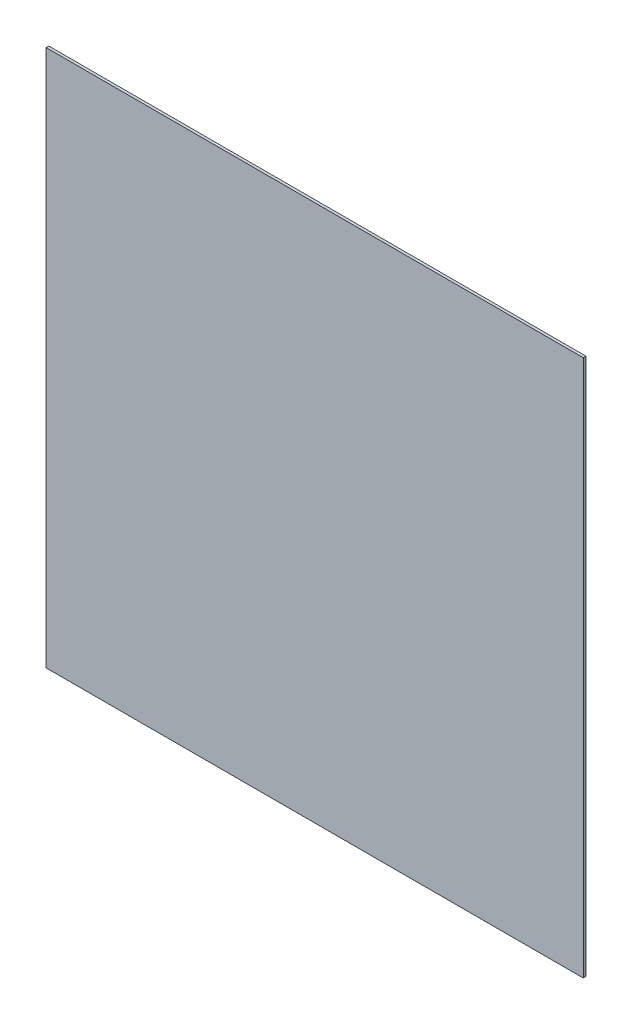
from build123d import *

# Parameters (mm, degrees)
SKETCH_1_W      = 200
SKETCH_1_H      = 200
EXTRUDE_1_DEPTH = 1


with BuildPart() as part:
    # 草图1 → 凸台-拉伸1 (new body)
    with BuildSketch(Plane.XY):
        Rectangle(SKETCH_1_W, SKETCH_1_H)
    extrude(amount=EXTRUDE_1_DEPTH)


solid = part.part
